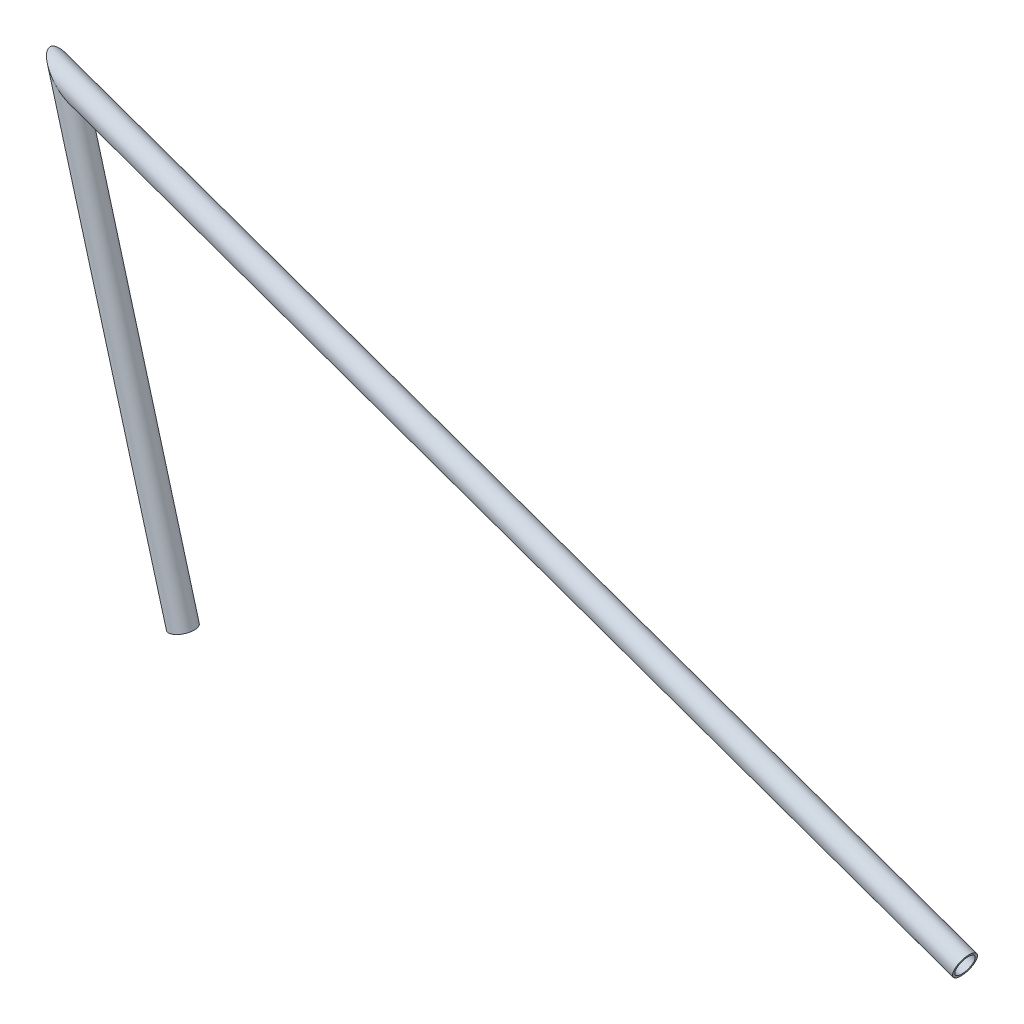
from build123d import *

# Parameters (mm, degrees)
SKETCH11_ON_SEGMENT_1_R         = 7.9375
SKETCH11_ON_SEGMENT_1_R_2       = 6.4643
STRUCTURAL_MEMBER1_DEPTH        = 658.886900495
SKETCH11_R                      = 7.9375
SKETCH11_R_2                    = 6.4643
STRUCTURAL_MEMBER1_2_DEPTH      = 289.285409962
STRUCTURAL_MEMBER1_2_DEPTH_BACK = 22.573683103


with BuildPart() as part:
    # Sketch11 on segment 1 (carried to segment 1) → Structural Member1 (new body)
    with BuildSketch(Plane(origin=(599.498795794, -213.29722096, 0), x_dir=(-0.335207906, -0.942144182, 0), z_dir=(-0.942144182, 0.335207906, 0))):
        Circle(SKETCH11_ON_SEGMENT_1_R)
        Circle(SKETCH11_ON_SEGMENT_1_R_2, mode=Mode.SUBTRACT)
    extrude(amount=STRUCTURAL_MEMBER1_DEPTH)

    # Structural Member1 mitre 1
    split(bisect_by=Plane(origin=(0, 0, 0), x_dir=(-0.68104996, 0.732236951, 0), z_dir=(0.732236951, 0.68104996, 0)), keep=Keep.TOP)


with BuildPart() as body_2:
    # Sketch11 → Structural Member1 2 (new, two sides)
    with BuildSketch(Plane(origin=(0, 0, 0), x_dir=(0.9639252411090171, 0.2661731195160835, 0), z_dir=(0.2661731195160835, -0.9639252411090171, 0))) as structural_member1_2_sk:
        Circle(SKETCH11_R)
        Circle(SKETCH11_R_2, mode=Mode.SUBTRACT)
    extrude(amount=STRUCTURAL_MEMBER1_2_DEPTH)
    extrude(structural_member1_2_sk.sketch, amount=-STRUCTURAL_MEMBER1_2_DEPTH_BACK)

    # Structural Member1 2 mitre 1
    split(bisect_by=Plane(origin=(0, 0, 0), x_dir=(0.68104996, -0.732236951, 0), z_dir=(-0.732236951, -0.68104996, 0)), keep=Keep.TOP)


solid = Compound([part.part, body_2.part])
